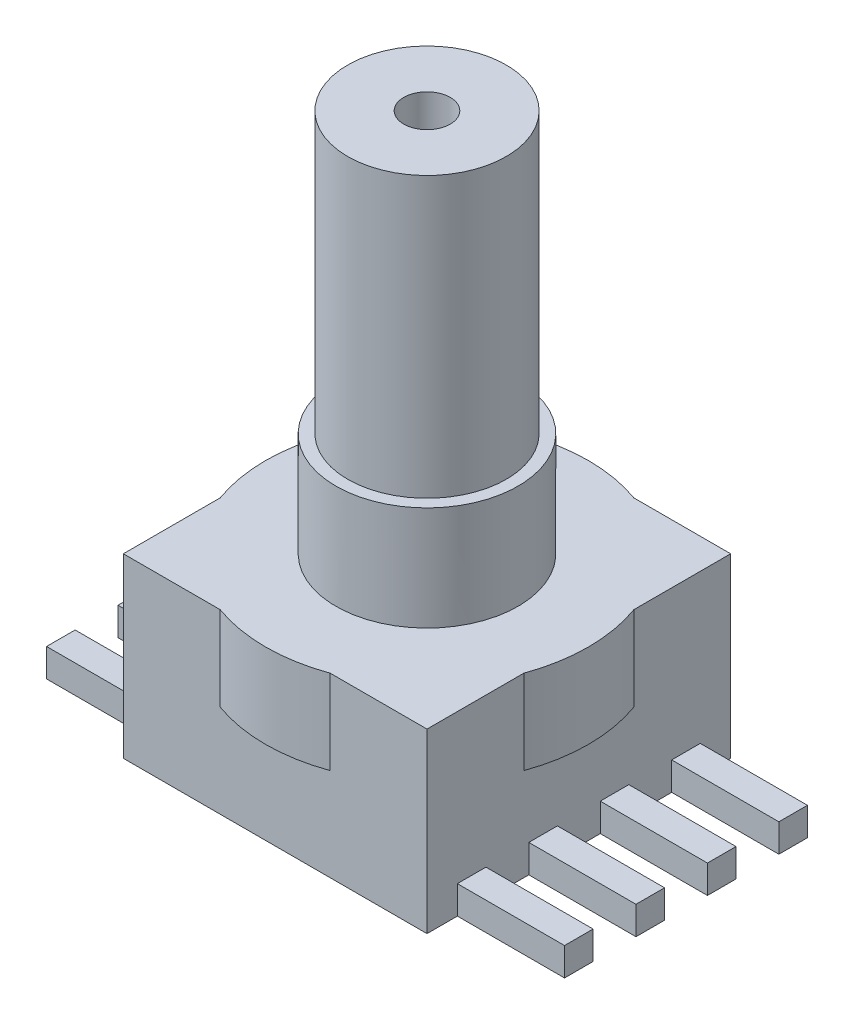
from build123d import *

# Parameters (mm, degrees)
SKETCH1_W           = 10.795
SKETCH1_H           = 10.795
BOSS_EXTRUDE1_DEPTH = 6.2992
SKETCH3_R           = 5.7404
BOSS_EXTRUDE2_DEPTH = 3
SKETCH4_R           = 2.8194
BOSS_EXTRUDE3_DEPTH = 19.939
SKETCH5_R           = 0.8255
CUT_EXTRUDE1_DEPTH  = 15
SKETCH7_R           = 3.2385
BOSS_EXTRUDE4_DEPTH = 10
SKETCH8_W           = 4.31
SKETCH8_H           = 1.016
BOSS_EXTRUDE5_DEPTH = 1


with BuildPart() as part:
    # Sketch1 → Boss-Extrude1 (new body)
    with BuildSketch(Plane(origin=(0, 0, 0), x_dir=(1, 0, 0), z_dir=(0, 1, 0))):
        Rectangle(SKETCH1_W, SKETCH1_H)
    extrude(amount=BOSS_EXTRUDE1_DEPTH)

    # Sketch3 → Boss-Extrude2 (add)
    with BuildSketch(Plane(origin=(0, 6.2992, 0), x_dir=(1, 0, 0), z_dir=(0, 1, 0))):
        Circle(SKETCH3_R)
    extrude(amount=-BOSS_EXTRUDE2_DEPTH)

    # Sketch4 → Boss-Extrude3 (add)
    with BuildSketch(Plane(origin=(0, 0, 0), x_dir=(1, 0, 0), z_dir=(0, 1, 0))):
        Circle(SKETCH4_R)
    extrude(amount=BOSS_EXTRUDE3_DEPTH)

    # Sketch5 → Cut-Extrude1 (cut)
    with BuildSketch(Plane(origin=(0, 19.939, 0), x_dir=(1, 0, 0), z_dir=(0, 1, 0))):
        Circle(SKETCH5_R)
    extrude(amount=-CUT_EXTRUDE1_DEPTH, mode=Mode.SUBTRACT)

    # Sketch7 → Boss-Extrude4 (add)
    with BuildSketch(Plane(origin=(0, 0, 0), x_dir=(1, 0, 0), z_dir=(0, 1, 0))):
        Circle(SKETCH7_R)
    extrude(amount=BOSS_EXTRUDE4_DEPTH)

    # Sketch8 → Boss-Extrude5 (add)
    with BuildSketch(Plane(origin=(0, 0, 0), x_dir=(1, 0, 0), z_dir=(0, 1, 0))):
        with Locations((-7.0525, 3.81)):
            Rectangle(SKETCH8_W, SKETCH8_H)
        with Locations((-7.0525, 1.27)):
            Rectangle(SKETCH8_W, SKETCH8_H)
        with Locations((-7.0525, -1.27)):
            Rectangle(SKETCH8_W, SKETCH8_H)
        with Locations((-7.0525, -3.81)):
            Rectangle(SKETCH8_W, SKETCH8_H)
        with Locations((7.0525, -3.81)):
            Rectangle(SKETCH8_W, SKETCH8_H)
        with Locations((7.0525, -1.27)):
            Rectangle(SKETCH8_W, SKETCH8_H)
        with Locations((7.0525, 1.27)):
            Rectangle(SKETCH8_W, SKETCH8_H)
        with Locations((7.0525, 3.81)):
            Rectangle(SKETCH8_W, SKETCH8_H)
    extrude(amount=BOSS_EXTRUDE5_DEPTH)


solid = part.part
